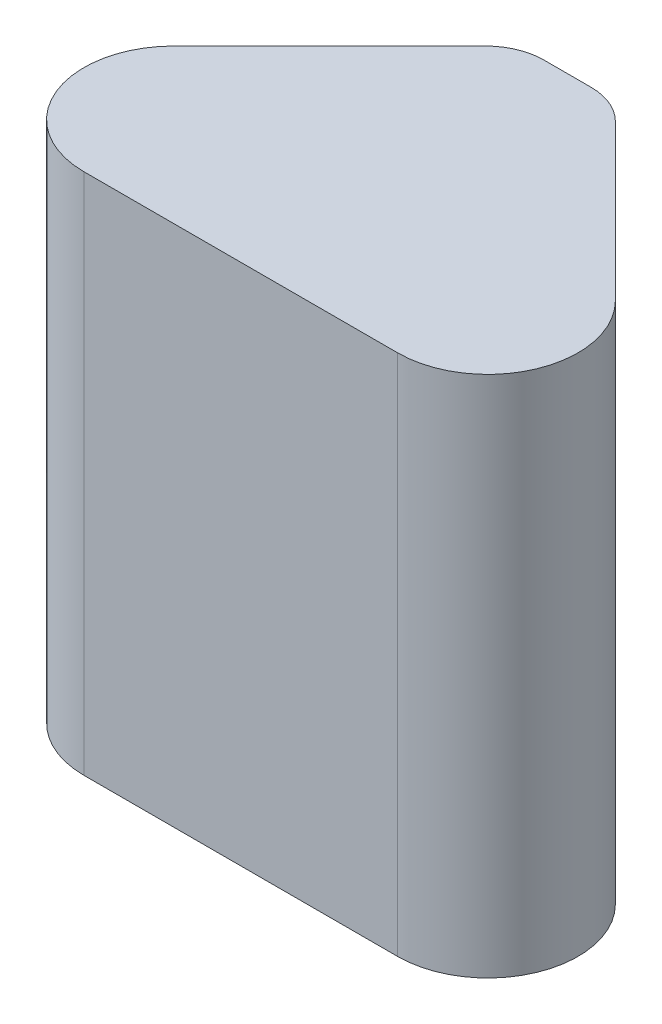
from build123d import *

# Parameters (mm, degrees)
BOSS_EXTRUDE1_DEPTH = 508


with BuildPart() as part:
    # Sketch1 → Boss-Extrude1 (new body)
    with BuildSketch(Plane(origin=(0, 0, 0), x_dir=(1, 0, 0), z_dir=(0, 1, 0))):
        with BuildLine():
            Line((-0.804837872, 185.266466712), (-46.499180652, 185.266466712))
            ThreePointArc((-46.499180652, 185.266466712), (-68.369538811, 180.916181995), (-86.910333197, 168.527619257))
            Line((-86.910333197, 168.527619257), (-238.077718506, 17.360233947))
            ThreePointArc((-238.077718506, 17.360233947), (-257.073514705, -78.138082466), (-176.113951271, -132.233533288))
            Line((-176.113951271, -132.233533288), (128.809932747, -132.233533288))
            ThreePointArc((128.809932747, -132.233533288), (209.769496181, -78.138082466), (190.773699982, 17.360233947))
            Line((190.773699982, 17.360233947), (39.606314673, 168.527619257))
            ThreePointArc((39.606314673, 168.527619257), (21.065520288, 180.916181995), (-0.804837872, 185.266466712))
        make_face()
    extrude(amount=BOSS_EXTRUDE1_DEPTH)


solid = part.part
